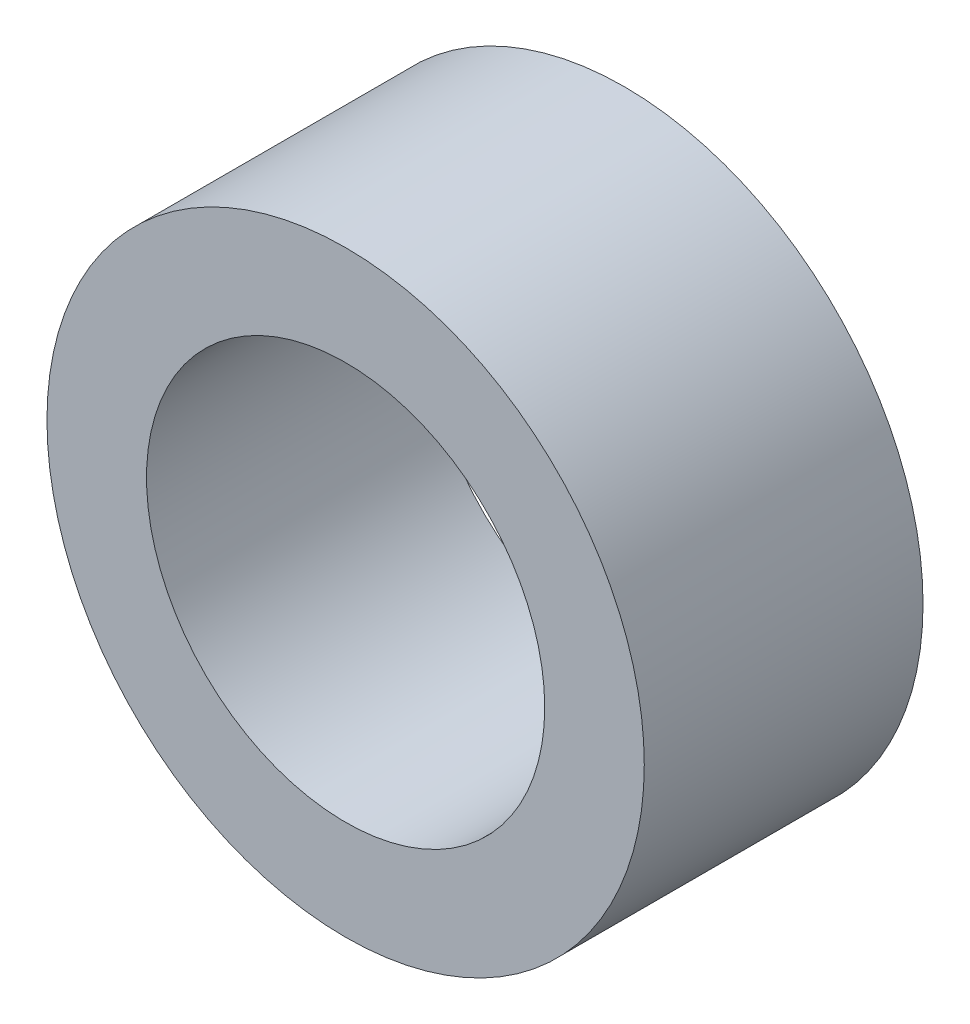
from build123d import *

# Parameters (mm, degrees)
SKETCH1_R           = 30
SKETCH1_R_2         = 20
BOSS_EXTRUDE1_DEPTH = 14


with BuildPart() as part:
    # Sketch1 → Boss-Extrude1 (new body, symmetric)
    with BuildSketch(Plane.XY):
        Circle(SKETCH1_R)
        Circle(SKETCH1_R_2, mode=Mode.SUBTRACT)
    extrude(amount=BOSS_EXTRUDE1_DEPTH, both=True)


solid = part.part
